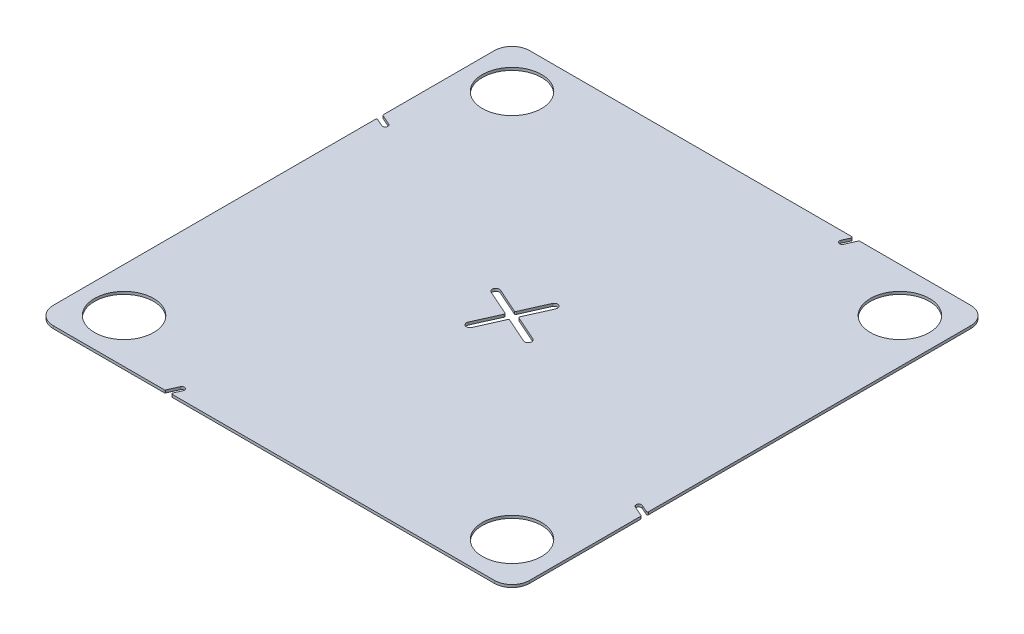
from build123d import *

# Parameters (mm, degrees)
SKETCH1_W           = 341.884
SKETCH1_H           = 341.884
BOSS_EXTRUDE1_DEPTH = 1.89738
SKETCH2_R           = 21.209
CUT_EXTRUDE1_DEPTH  = 2.89738
FILLET2_R           = 12.7
CUT_EXTRUDE3_DEPTH  = 2.89738
FILLET3_R           = 0.762


with BuildPart() as part:
    # Sketch1 → Boss-Extrude1 (new body)
    with BuildSketch(Plane(origin=(0, 0, 0), x_dir=(1, 0, 0), z_dir=(0, 1, 0))):
        Rectangle(SKETCH1_W, SKETCH1_H)
    extrude(amount=BOSS_EXTRUDE1_DEPTH)

    # Sketch2 → Cut-Extrude1 (cut, through all)
    with BuildSketch(Plane(origin=(0, 1.89738, 0), x_dir=(1, 0, 0), z_dir=(0, 1, 0))):
        with Locations((-139.192, -139.192)):
            Circle(SKETCH2_R)
        with Locations((-139.192, 139.192)):
            Circle(SKETCH2_R)
        with Locations((139.192, 139.192)):
            Circle(SKETCH2_R)
        with Locations((139.192, -139.192)):
            Circle(SKETCH2_R)
    extrude(amount=-CUT_EXTRUDE1_DEPTH, mode=Mode.SUBTRACT)

    # Fillet2
    fillet2_edges = [part.edges().sort_by_distance(p)[0] for p in [
        (-170.942, 0.94869, -170.942),
        (170.942, 0.94869, -170.942),
        (170.942, 0.94869, 170.942),
        (-170.942, 0.94869, 170.942),
    ]]
    fillet(fillet2_edges, radius=FILLET2_R)

    # Sketch6 → Cut-Extrude3 (cut, through all)
    with BuildSketch(Plane(origin=(0, 1.89738, 0), x_dir=(1, 0, 0), z_dir=(0, 1, 0))):
        with BuildLine():
            Line((6.977594198, 21.916760235), (-1.287294389, 3.353516536))
            Line((-1.287294389, 3.353516536), (-19.850538088, 11.618405123))
            ThreePointArc((-19.850538088, 11.618405123), (-23.204054624, 10.331110734), (-21.916760235, 6.977594198))
            Line((-21.916760235, 6.977594198), (-3.353516536, -1.287294389))
            Line((-3.353516536, -1.287294389), (-11.618405123, -19.850538088))
            ThreePointArc((-11.618405123, -19.850538088), (-10.331110734, -23.204054624), (-6.977594198, -21.916760235))
            Line((-6.977594198, -21.916760235), (1.287294389, -3.353516536))
            Line((1.287294389, -3.353516536), (19.850538088, -11.618405123))
            ThreePointArc((19.850538088, -11.618405123), (23.204054624, -10.331110734), (21.916760235, -6.977594198))
            Line((21.916760235, -6.977594198), (3.353516536, 1.287294389))
            Line((3.353516536, 1.287294389), (11.618405123, 19.850538088))
            ThreePointArc((11.618405123, 19.850538088), (10.331110734, 23.204054624), (6.977594198, 21.916760235))
        make_face()
        with BuildLine():
            Line((-170.942, 78.193564035), (-163.205950308, 74.749252801))
            ThreePointArc((-163.205950308, 74.749252801), (-162.240479516, 72.234115399), (-164.755616918, 71.268644607))
            Line((-164.755616918, 71.268644607), (-170.942, 74.022999813))
            Line((-170.942, 74.022999813), (-170.942, 78.193564035))
        make_face()
        with BuildLine():
            Line((74.022999813, 170.942), (78.193564035, 170.942))
            Line((78.193564035, 170.942), (74.749252801, 163.205950308))
            ThreePointArc((74.749252801, 163.205950308), (72.234115399, 162.240479516), (71.268644607, 164.755616918))
            Line((71.268644607, 164.755616918), (74.022999813, 170.942))
        make_face()
        with BuildLine():
            Line((170.942, -74.022999813), (170.942, -78.193564035))
            Line((170.942, -78.193564035), (163.205950308, -74.749252801))
            ThreePointArc((163.205950308, -74.749252801), (162.240479516, -72.234115399), (164.755616918, -71.268644607))
            Line((164.755616918, -71.268644607), (170.942, -74.022999813))
        make_face()
        with BuildLine():
            Line((-74.022999813, -170.942), (-78.193564035, -170.942))
            Line((-78.193564035, -170.942), (-74.749252801, -163.205950308))
            ThreePointArc((-74.749252801, -163.205950308), (-72.234115399, -162.240479516), (-71.268644607, -164.755616918))
            Line((-71.268644607, -164.755616918), (-74.022999813, -170.942))
        make_face()
    extrude(amount=-CUT_EXTRUDE3_DEPTH, mode=Mode.SUBTRACT)

    # Fillet3
    fillet3_edges = [part.edges().sort_by_distance(p)[0] for p in [
        (78.193564035, 0.94869, -170.942),
        (74.022999813, 0.94869, -170.942),
        (-170.942, 0.94869, -74.022999813),
        (-170.942, 0.94869, -78.193564035),
        (3.353516536, 0.94869, -1.287294389),
        (1.287294389, 0.94869, 3.353516536),
        (-3.353516536, 0.94869, 1.287294389),
        (-1.287294389, 0.94869, -3.353516536),
        (-78.193564035, 0.94869, 170.942),
        (-74.022999813, 0.94869, 170.942),
        (170.942, 0.94869, 78.193564035),
        (170.942, 0.94869, 74.022999813),
    ]]
    fillet(fillet3_edges, radius=FILLET3_R)


solid = part.part
